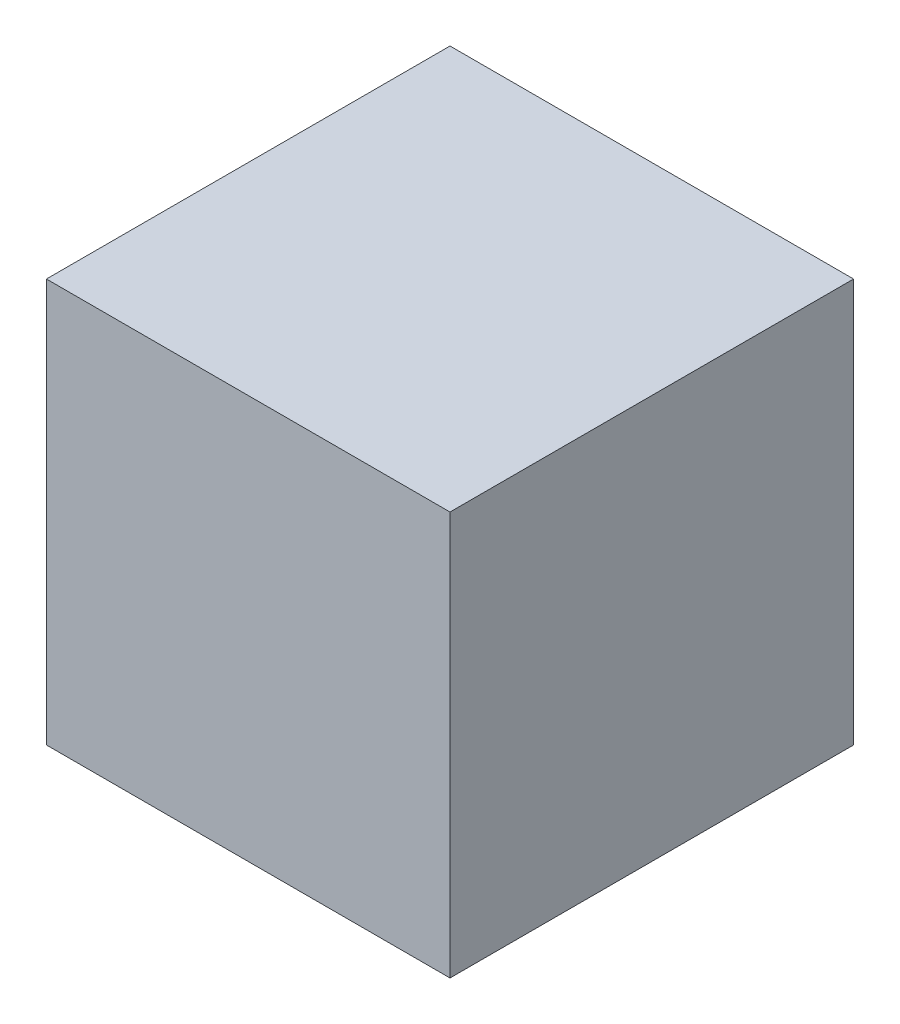
from build123d import *

# Parameters (mm, degrees)
SKIZZE1_W                       = 53
SKIZZE1_H                       = 53
AUFSATZ_LINEAR_AUSTRAGEN3_DEPTH = 26.5


with BuildPart() as part:
    # Skizze1 → Aufsatz-Linear austragen3 (new body, symmetric)
    with BuildSketch(Plane(origin=(0, 0, 0), x_dir=(1, 0, 0), z_dir=(0, 1, 0))):
        Rectangle(SKIZZE1_W, SKIZZE1_H)
    extrude(amount=AUFSATZ_LINEAR_AUSTRAGEN3_DEPTH, both=True)


solid = part.part
